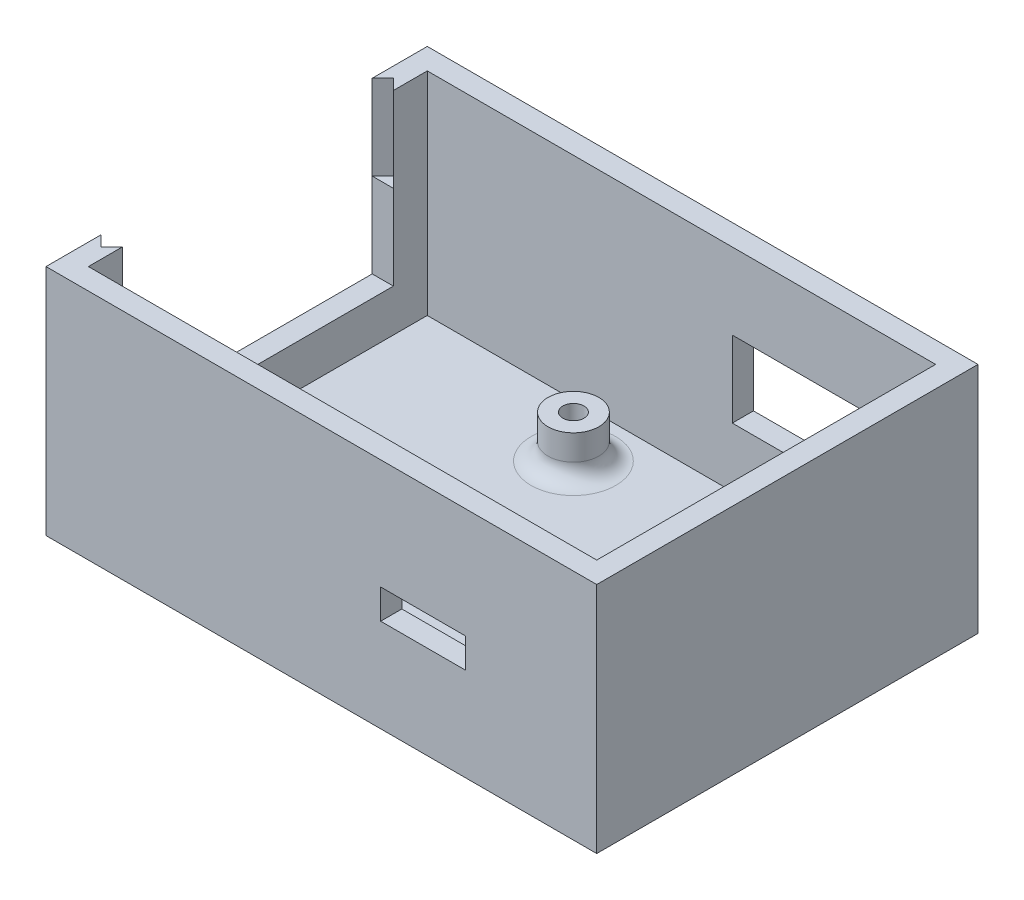
from build123d import *

# Parameters (mm, degrees)
SKETCH_1_W          = 65
SKETCH_1_H          = 45
EXTRUDE_1_DEPTH     = 27.5
SHELL_1_T           = -2.5
SKETCH_3_W          = 32
SKETCH_3_H          = 20
CUT_EXTRUDE_1_DEPTH = 3.5
CUT_EXTRUDE_2_DEPTH = 10
SKETCH_5_R          = 3
SKETCH_5_R_2        = 1.25
EXTRUDE_2_DEPTH     = 5
SKETCH_6_R          = 3
SKETCH_6_R_2        = 0.75
EXTRUDE_3_DEPTH     = 5
SKETCH_7_W          = 22
SKETCH_7_H          = 9
CUT_EXTRUDE_3_DEPTH = 3.5
SKETCH_8_W          = 10
SKETCH_8_H          = 3.5
CUT_EXTRUDE_4_DEPTH = 3.5
FILLET_1_R          = 2


with BuildPart() as part:
    # 草图1 → 凸台-拉伸1 (new body)
    with BuildSketch(Plane(origin=(0, 0, 0), x_dir=(1, 0, 0), z_dir=(0, 1, 0))):
        Rectangle(SKETCH_1_W, SKETCH_1_H)
    extrude(amount=EXTRUDE_1_DEPTH)

    # 抽壳1
    shell_1_openings = [part.faces().sort_by_distance(p)[0] for p in [
        (0, 27.5, 0),
    ]]
    offset(amount=SHELL_1_T, openings=shell_1_openings, kind=Kind.INTERSECTION)

    # 草图3 → 切除-拉伸1 (cut, through all)
    with BuildSketch(Plane(origin=(-30, 0, 0), x_dir=(0, 0, -1), z_dir=(1, 0, 0))):
        with Locations((0, 17.5)):
            Rectangle(SKETCH_3_W, SKETCH_3_H)
    extrude(amount=-CUT_EXTRUDE_1_DEPTH, mode=Mode.SUBTRACT)

    # 草图4 → 切除-拉伸2 (cut)
    with BuildSketch(Plane(origin=(0, 27.5, 0), x_dir=(1, 0, 0), z_dir=(0, 1, 0))):
        Polygon((-32.5, 16), (-31.25, 17.25), (-30, 16), align=None)
        Polygon((-32.5, -16), (-30, -16), (-31.25, -17.25), align=None)
    extrude(amount=-CUT_EXTRUDE_2_DEPTH, mode=Mode.SUBTRACT)

    # 草图5 → 凸台-拉伸2 (add)
    with BuildSketch(Plane(origin=(0, 2.5, 0), x_dir=(1, 0, 0), z_dir=(0, 1, 0))):
        with Locations((-6.5, 13.75)):
            Circle(SKETCH_5_R)
        with Locations((-6.5, 13.75)):
            Circle(SKETCH_5_R_2, mode=Mode.SUBTRACT)
        with Locations((-6.5, -13.75)):
            Circle(SKETCH_5_R)
        with Locations((-6.5, -13.75)):
            Circle(SKETCH_5_R_2, mode=Mode.SUBTRACT)
    extrude(amount=EXTRUDE_2_DEPTH)

    # 草图6 → 凸台-拉伸3 (add)
    with BuildSketch(Plane(origin=(0, 2.5, 0), x_dir=(1, 0, 0), z_dir=(0, 1, 0))):
        with Locations((20, -7)):
            Circle(SKETCH_6_R)
        with Locations((20, -7)):
            Circle(SKETCH_6_R_2, mode=Mode.SUBTRACT)
    extrude(amount=EXTRUDE_3_DEPTH)

    # 草图7 → 切除-拉伸3 (cut, through all)
    with BuildSketch(Plane.XY.offset(-20)):
        with Locations((17, 14)):
            Rectangle(SKETCH_7_W, SKETCH_7_H)
    extrude(amount=-CUT_EXTRUDE_3_DEPTH, mode=Mode.SUBTRACT)

    # 草图8 → 切除-拉伸4 (cut, through all)
    with BuildSketch(Plane(origin=(0, 0, 20), x_dir=(-1, 0, 0), z_dir=(0, 0, -1))):
        with Locations((-12, 12.75)):
            Rectangle(SKETCH_8_W, SKETCH_8_H)
    extrude(amount=-CUT_EXTRUDE_4_DEPTH, mode=Mode.SUBTRACT)

    # 圆角1
    fillet_1_edges = [part.edges().sort_by_distance(p)[0] for p in [
        (-9.5, 2.5, -13.75),
        (-9.5, 2.5, 13.75),
        (17, 2.5, 7),
    ]]
    fillet(fillet_1_edges, radius=FILLET_1_R)


solid = part.part
